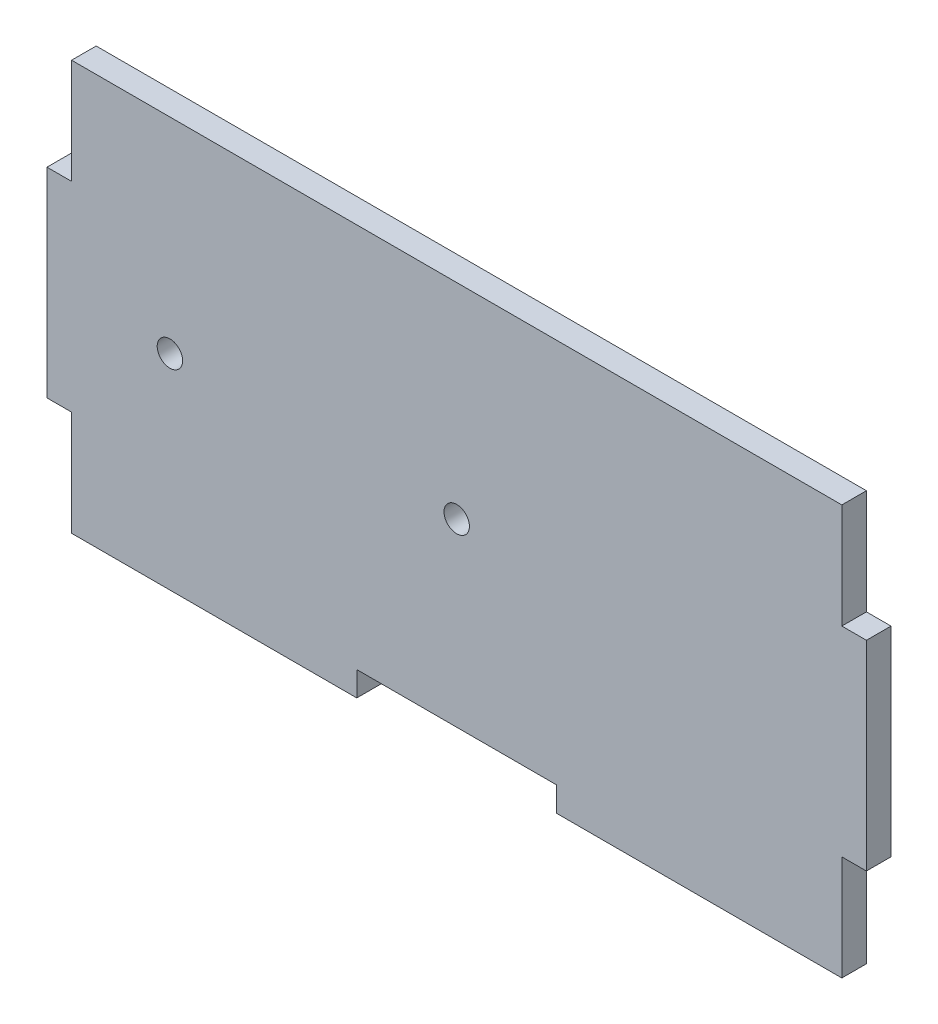
from build123d import *

# Parameters (mm, degrees)
SALIENTE_EXTRUIR1_DEPTH = 3
CROQUIS2_R              = 1.55
CORTAR_EXTRUIR1_DEPTH   = 3


with BuildPart() as part:
    # Model → Saliente-Extruir1 (new body)
    with BuildSketch(Plane.XY):
        Polygon((186, 103), (186, 90.195), (183, 90.195), (183, 65.805), (186, 65.805), (186, 53), (220.805, 53), (220.805, 56), (245.195, 56), (245.195, 53), (269.585, 53), (280, 53), (280, 65.805), (283, 65.805), (283, 90.195), (280, 90.195), (280, 103), align=None)
    extrude(amount=SALIENTE_EXTRUIR1_DEPTH)

    # Croquis2 → Cortar-Extruir1 (cut)
    with BuildSketch(Plane.XY.offset(3)):
        with Locations((233, 78)):
            Circle(CROQUIS2_R)
        with Locations((198, 78)):
            Circle(CROQUIS2_R)
    extrude(amount=-CORTAR_EXTRUIR1_DEPTH, mode=Mode.SUBTRACT)


solid = part.part
